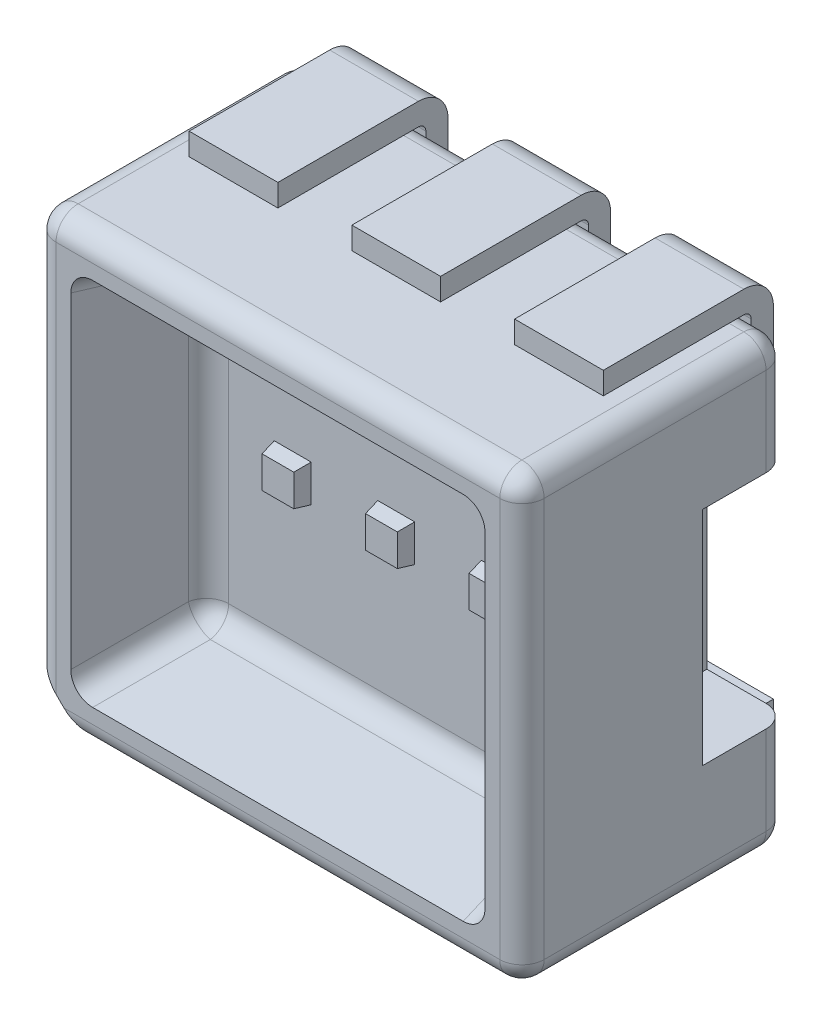
from build123d import *

# Parameters (mm, degrees)
SKETCH1_W            = 3.3
SKETCH1_H            = 3
BOSS_EXTRUDE1_DEPTH  = 1.8
CUT_EXTRUDE2_DEPTH   = 0.4
SKETCH2_W            = 2.8
SKETCH2_H            = 2.5
CUT_EXTRUDE1_DEPTH   = 0.8
CUT_EXTRUDE1_TAPER   = 10
FILLET1_R            = 0.15
EXTRUDE_THIN1_DEPTH  = 0.3
LPATTERN1_COUNT      = 3
LPATTERN1_PITCH      = 1.1
MIRROR1_COPY_1_DEPTH = 0.3
MIRROR1_COPY_2_DEPTH = 0.3
SKETCH5_R            = 0.04
CUT_EXTRUDE3_DEPTH   = 0.1
SKETCH6_W            = 0.25
SKETCH6_H            = 0.25
BOSS_EXTRUDE2_DEPTH  = 0.1
BOSS_EXTRUDE2_TAPER  = 10
LPATTERN2_COUNT      = 3
LPATTERN2_PITCH      = 0.7
SKETCH7_W            = 0.55
SKETCH7_H            = 0.58
CUT_EXTRUDE4_DEPTH   = 0.75


with BuildPart() as part:
    # Sketch1 → Boss-Extrude1 (new body)
    with BuildSketch(Plane.XY):
        with Locations((1.65, 1.5)):
            Rectangle(SKETCH1_W, SKETCH1_H)
    extrude(amount=BOSS_EXTRUDE1_DEPTH)

    # Sketch4 → Cut-Extrude2 (cut)
    with BuildSketch(Plane.XY.offset(1.8)):
        Polygon((0, 0.353553391), (0.353553391, 0), (0, 0), align=None)
    extrude(amount=-CUT_EXTRUDE2_DEPTH, mode=Mode.SUBTRACT)

    # Sketch2 → Cut-Extrude1 (cut)
    with BuildSketch(Plane.XY.offset(1.8)):
        with Locations((1.65, 1.5)):
            Rectangle(SKETCH2_W, SKETCH2_H)
    extrude(amount=-CUT_EXTRUDE1_DEPTH, taper=CUT_EXTRUDE1_TAPER, mode=Mode.SUBTRACT)

    # Fillet1
    fillet1_edges = [part.edges().sort_by_distance(p)[0] for p in [
        (3.3, 1.5, 1.8),
        (1.65, 3, 1.8),
        (1.826776695, 0, 1.8),
        (0, 0, 0.7),
        (0.391061585, 1.5, 1),
        (0.320530792, 0.320530792, 1.4),
        (1.65, 2.608938415, 1),
        (0.320530792, 2.679469208, 1.4),
        (2.908938415, 1.5, 1),
        (2.979469208, 2.679469208, 1.4),
        (1.65, 0.391061585, 1),
        (2.979469208, 0.320530792, 1.4),
        (0, 1.676776695, 1.8),
        (1.65, 3, 0),
        (3.3, 1.5, 0),
        (1.65, 0, 0),
        (0, 1.5, 0),
        (0, 3, 0.9),
        (3.3, 3, 0.9),
        (3.3, 0, 0.9),
    ]]
    fillet(fillet1_edges, radius=FILLET1_R)

    # Sketch3 → Extrude-Thin1 (add, symmetric)
    with BuildSketch(Plane(origin=(0.55, 0, 0), x_dir=(0, 0, -1), z_dir=(1, 0, 0))):
        with BuildLine():
            Line((-1, 3), (-0.05, 3))
            ThreePointArc((-0.05, 3), (-0.014644661, 2.985355339), (0, 2.95))
            Line((0, 2.95), (0, 2.35))
            Line((0, 2.35), (0.15, 2.35))
            Line((0.15, 2.35), (0.15, 2.95))
            ThreePointArc((0.15, 2.95), (0.091421356, 3.091421356), (-0.05, 3.15))
            Line((-0.05, 3.15), (-1, 3.15))
            Line((-1, 3.15), (-1, 3))
        make_face()
    extrude_thin1 = extrude(amount=EXTRUDE_THIN1_DEPTH, both=True)

    # LPattern1: Extrude-Thin1 ×3
    with Locations(*[(i * LPATTERN1_PITCH, 0, 0) for i in range(1, LPATTERN1_COUNT)]):
        add(extrude_thin1)

    # Mirror1: Extrude-Thin1 across plane
    add(extrude_thin1.mirror(Plane.ZX.offset(1.5)))

    # Mirror1 copy 1 sketch → Mirror1 copy 1 (add, symmetric)
    with BuildSketch(Plane(origin=(1.65, 3, 0), x_dir=(0, 0, -1), z_dir=(1, 0, 0))):
        with BuildLine():
            Line((-1, -3), (-0.05, -3))
            ThreePointArc((-0.05, -3), (-0.014644661, -2.985355339), (0, -2.95))
            Line((0, -2.95), (0, -2.35))
            Line((0, -2.35), (0.15, -2.35))
            Line((0.15, -2.35), (0.15, -2.95))
            ThreePointArc((0.15, -2.95), (0.091421356, -3.091421356), (-0.05, -3.15))
            Line((-0.05, -3.15), (-1, -3.15))
            Line((-1, -3.15), (-1, -3))
        make_face()
    extrude(amount=MIRROR1_COPY_1_DEPTH, both=True)

    # Mirror1 copy 2 sketch → Mirror1 copy 2 (add, symmetric)
    with BuildSketch(Plane(origin=(2.75, 3, 0), x_dir=(0, 0, -1), z_dir=(1, 0, 0))):
        with BuildLine():
            Line((-1, -3), (-0.05, -3))
            ThreePointArc((-0.05, -3), (-0.014644661, -2.985355339), (0, -2.95))
            Line((0, -2.95), (0, -2.35))
            Line((0, -2.35), (0.15, -2.35))
            Line((0.15, -2.35), (0.15, -2.95))
            ThreePointArc((0.15, -2.95), (0.091421356, -3.091421356), (-0.05, -3.15))
            Line((-0.05, -3.15), (-1, -3.15))
            Line((-1, -3.15), (-1, -3))
        make_face()
    extrude(amount=MIRROR1_COPY_2_DEPTH, both=True)

    # Sketch5 → Cut-Extrude3 (cut)
    with BuildSketch(Plane.XY.offset(1.4)):
        with Locations((0.11, 0.11)):
            Circle(SKETCH5_R)
    extrude(amount=-CUT_EXTRUDE3_DEPTH, mode=Mode.SUBTRACT)

    # Sketch6 → Boss-Extrude2 (add)
    with BuildSketch(Plane.XY.offset(1)):
        with Locations((0.95, 1.5)):
            Rectangle(SKETCH6_W, SKETCH6_H)
    boss_extrude2 = extrude(amount=BOSS_EXTRUDE2_DEPTH, taper=BOSS_EXTRUDE2_TAPER)

    # LPattern2: Boss-Extrude2 ×3
    with Locations(*[(i * LPATTERN2_PITCH, 0, 0) for i in range(1, LPATTERN2_COUNT)]):
        add(boss_extrude2)

    # Sketch7 → Cut-Extrude4 (cut, symmetric)
    with BuildSketch(Plane(origin=(0, 1.5, 0), x_dir=(1, 0, 0), z_dir=(0, 1, 0))):
        with Locations((0.275, -0.29)):
            Rectangle(SKETCH7_W, SKETCH7_H)
    cut_extrude4 = extrude(amount=CUT_EXTRUDE4_DEPTH, both=True, mode=Mode.SUBTRACT)

    # Mirror2: Cut-Extrude4 across plane
    add(cut_extrude4.mirror(Plane(origin=(1.65, 0, 0), x_dir=(0, 0, 1), z_dir=(1, 0, 0))), mode=Mode.SUBTRACT)


solid = part.part
